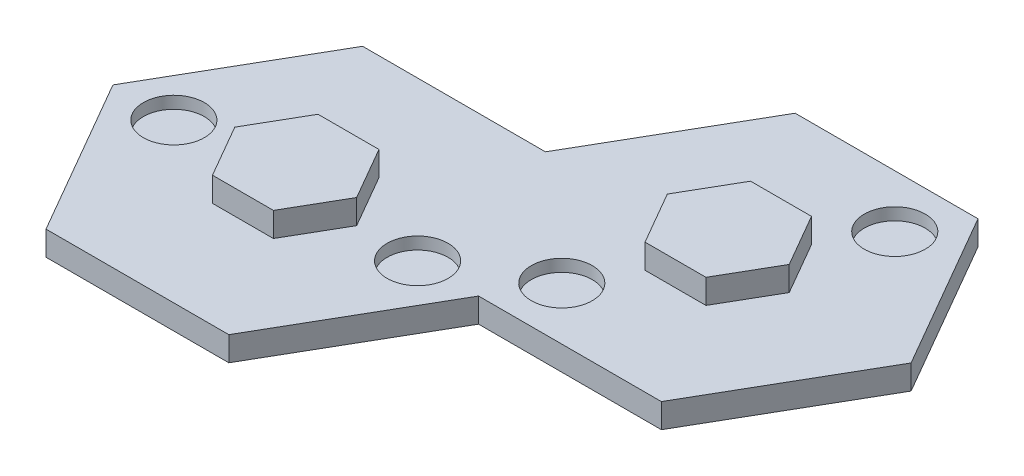
from build123d import *

# Parameters (mm, degrees)
BOSS_EXTRUDE1_DEPTH = 10.16
SKETCH2_R           = 12.7
CUT_EXTRUDE1_DEPTH  = 5.08
BOSS_EXTRUDE2_DEPTH = 10.16


with BuildPart() as part:
    # Sketch1 → Boss-Extrude1 (new body)
    with BuildSketch(Plane(origin=(0, 0, 0), x_dir=(1, 0, 0), z_dir=(0, 1, 0))):
        Polygon((38.1, 65.991135768), (-38.1, 65.991135768), (-76.2, 0), (-38.1, -65.991135768), (38.1, -65.991135768), (76.2, 0), align=None)
    boss_extrude1 = extrude(amount=BOSS_EXTRUDE1_DEPTH)

    # Sketch2 → Cut-Extrude1 (cut)
    with BuildSketch(Plane(origin=(0, 10.16, 0), x_dir=(1, 0, 0), z_dir=(0, 1, 0))):
        with Locations((-50.8, 0)):
            Circle(SKETCH2_R)
        with Locations((50.8, 0)):
            Circle(SKETCH2_R)
    cut_extrude1 = extrude(amount=-CUT_EXTRUDE1_DEPTH, mode=Mode.SUBTRACT)

    # Mirror1: Boss-Extrude1, Cut-Extrude1 across plane
    add(boss_extrude1.mirror(Plane(origin=(76.2, 10.16, 0), x_dir=(0.5, 0, 0.866025404), z_dir=(-0.866025404, 0, 0.5))))
    add(cut_extrude1.mirror(Plane(origin=(76.2, 10.16, 0), x_dir=(0.5, 0, 0.866025404), z_dir=(-0.866025404, 0, 0.5))), mode=Mode.SUBTRACT)

    # Sketch3 → Boss-Extrude2 (add)
    with BuildSketch(Plane(origin=(0, 10.16, 0), x_dir=(1, 0, 0), z_dir=(0, 1, 0))):
        Polygon((12.7, 21.997045256), (-12.7, 21.997045256), (-25.4, 0), (-12.7, -21.997045256), (12.7, -21.997045256), (25.4, 0), align=None)
    boss_extrude2 = extrude(amount=BOSS_EXTRUDE2_DEPTH)

    # Mirror2: Boss-Extrude2 across plane
    add(boss_extrude2.mirror(Plane(origin=(57.15, 0, -32.995567884), x_dir=(0.5, 0, 0.866025404), z_dir=(0.866025404, 0, -0.5))))


solid = part.part
